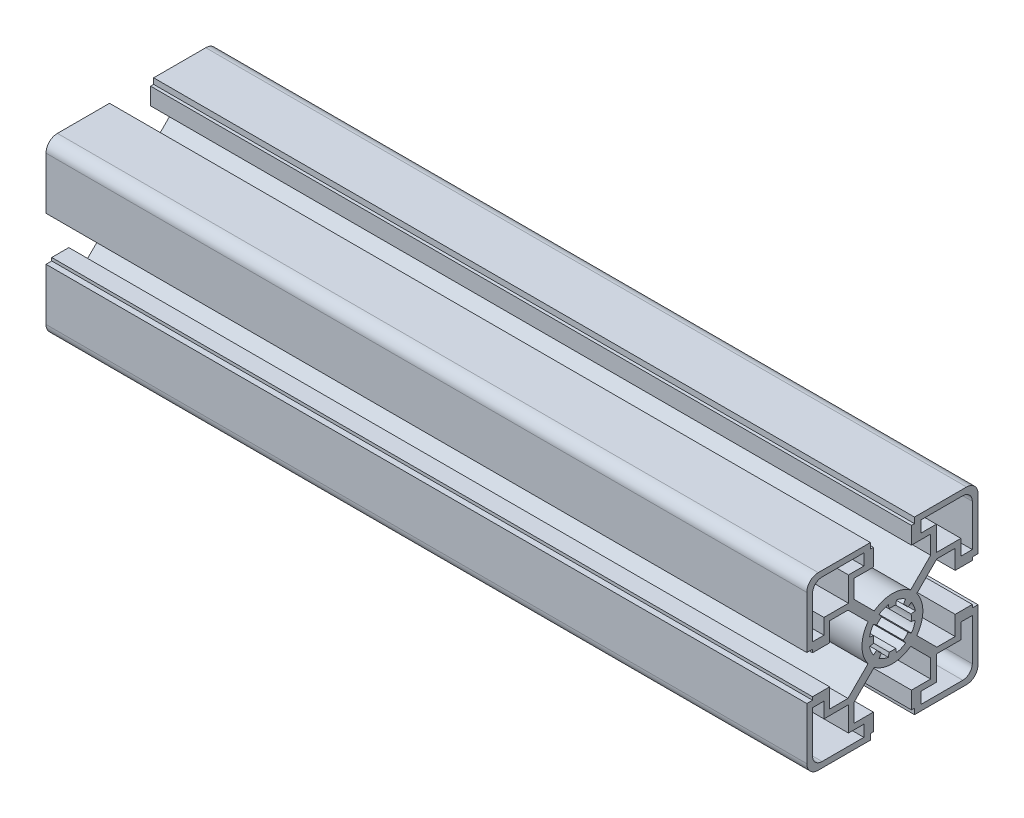
from build123d import *

# Parameters (mm, degrees)
BR_EXTRUDE_DEPTH      = 122.5
BR_EXTRUDE_DEPTH_BACK = 77.5


with BuildPart() as part:
    # Sketch2 → BR_Extrude (new body, two sides)
    with BuildSketch(Plane(origin=(0, 0, 0), x_dir=(0, 0, -1), z_dir=(1, 0, 0))) as br_extrude_sk:
        with BuildLine():
            Line((-10.05, 11.676345597), (-10.05, 16.5))
            Line((-10.05, 16.5), (-5, 16.5))
            Line((-5, 16.5), (-5, 21))
            Line((-5, 21), (-5.8, 21))
            Line((-5.8, 21), (-5.8, 22.5))
            Line((-5.8, 22.5), (-19.5, 22.5))
            ThreePointArc((-19.5, 22.5), (-21.621320344, 21.621320344), (-22.5, 19.5))
            Line((-22.5, 19.5), (-22.5, 5.8))
            Line((-22.5, 5.8), (-21, 5.8))
            Line((-21, 5.8), (-21, 5))
            Line((-21, 5), (-16.5, 5))
            Line((-16.5, 5), (-16.5, 10.05))
            Line((-16.5, 10.05), (-11.676345597, 10.05))
            Line((-11.676345597, 10.05), (-6.411275155, 4.784929559))
            ThreePointArc((-6.411275155, 4.784929559), (-8, 0), (-6.411275155, -4.784929559))
            Line((-6.411275155, -4.784929559), (-11.676345597, -10.05))
            Line((-11.676345597, -10.05), (-16.5, -10.05))
            Line((-16.5, -10.05), (-16.5, -5))
            Line((-16.5, -5), (-21, -5))
            Line((-21, -5), (-21, -5.8))
            Line((-21, -5.8), (-22.5, -5.8))
            Line((-22.5, -5.8), (-22.5, -19.5))
            ThreePointArc((-22.5, -19.5), (-21.621320344, -21.621320344), (-19.5, -22.5))
            Line((-19.5, -22.5), (-5.8, -22.5))
            Line((-5.8, -22.5), (-5.8, -21))
            Line((-5.8, -21), (-5, -21))
            Line((-5, -21), (-5, -16.5))
            Line((-5, -16.5), (-10.05, -16.5))
            Line((-10.05, -16.5), (-10.05, -11.676345597))
            Line((-10.05, -11.676345597), (-4.784929559, -6.411275155))
            ThreePointArc((-4.784929559, -6.411275155), (0, -8), (4.784929559, -6.411275155))
            Line((4.784929559, -6.411275155), (10.05, -11.676345597))
            Line((10.05, -11.676345597), (10.05, -16.5))
            Line((10.05, -16.5), (5, -16.5))
            Line((5, -16.5), (5, -21))
            Line((5, -21), (5.8, -21))
            Line((5.8, -21), (5.8, -22.5))
            Line((5.8, -22.5), (19.5, -22.5))
            ThreePointArc((19.5, -22.5), (21.621320344, -21.621320344), (22.5, -19.5))
            Line((22.5, -19.5), (22.5, -5.8))
            Line((22.5, -5.8), (21, -5.8))
            Line((21, -5.8), (21, -5))
            Line((21, -5), (16.5, -5))
            Line((16.5, -5), (16.5, -10.05))
            Line((16.5, -10.05), (11.676345597, -10.05))
            Line((11.676345597, -10.05), (6.411275155, -4.784929559))
            ThreePointArc((6.411275155, -4.784929559), (8, 0), (6.411275155, 4.784929559))
            Line((6.411275155, 4.784929559), (11.676345597, 10.05))
            Line((11.676345597, 10.05), (16.5, 10.05))
            Line((16.5, 10.05), (16.5, 5))
            Line((16.5, 5), (21, 5))
            Line((21, 5), (21, 5.8))
            Line((21, 5.8), (22.5, 5.8))
            Line((22.5, 5.8), (22.5, 19.5))
            ThreePointArc((22.5, 19.5), (21.621320344, 21.621320344), (19.5, 22.5))
            Line((19.5, 22.5), (5.8, 22.5))
            Line((5.8, 22.5), (5.8, 21))
            Line((5.8, 21), (5, 21))
            Line((5, 21), (5, 16.5))
            Line((5, 16.5), (10.05, 16.5))
            Line((10.05, 16.5), (10.05, 11.676345597))
            Line((10.05, 11.676345597), (4.784929559, 6.411275155))
            ThreePointArc((4.784929559, 6.411275155), (0, 8), (-4.784929559, 6.411275155))
            Line((-4.784929559, 6.411275155), (-10.05, 11.676345597))
        make_face()
        with BuildLine():
            Line((11.55, 11.55), (11.55, 18))
            Line((11.55, 18), (7.5, 18))
            Line((7.5, 18), (7.5, 21))
            Line((7.5, 21), (18.5, 21))
            ThreePointArc((18.5, 21), (20.267766953, 20.267766953), (21, 18.5))
            Line((21, 18.5), (21, 7.5))
            Line((21, 7.5), (18, 7.5))
            Line((18, 7.5), (18, 11.55))
            Line((18, 11.55), (11.55, 11.55))
        make_face(mode=Mode.SUBTRACT)
        with BuildLine():
            Line((11.55, -11.55), (18, -11.55))
            Line((18, -11.55), (18, -7.5))
            Line((18, -7.5), (21, -7.5))
            Line((21, -7.5), (21, -18.5))
            ThreePointArc((21, -18.5), (20.267766953, -20.267766953), (18.5, -21))
            Line((18.5, -21), (7.5, -21))
            Line((7.5, -21), (7.5, -18))
            Line((7.5, -18), (11.55, -18))
            Line((11.55, -18), (11.55, -11.55))
        make_face(mode=Mode.SUBTRACT)
        with BuildLine():
            Line((-11.55, 11.55), (-18, 11.55))
            Line((-18, 11.55), (-18, 7.5))
            Line((-18, 7.5), (-21, 7.5))
            Line((-21, 7.5), (-21, 18.5))
            ThreePointArc((-21, 18.5), (-20.267766953, 20.267766953), (-18.5, 21))
            Line((-18.5, 21), (-7.5, 21))
            Line((-7.5, 21), (-7.5, 18))
            Line((-7.5, 18), (-11.55, 18))
            Line((-11.55, 18), (-11.55, 11.55))
        make_face(mode=Mode.SUBTRACT)
        with BuildLine():
            Line((-11.55, -11.55), (-11.55, -18))
            Line((-11.55, -18), (-7.5, -18))
            Line((-7.5, -18), (-7.5, -21))
            Line((-7.5, -21), (-18.5, -21))
            ThreePointArc((-18.5, -21), (-20.267766953, -20.267766953), (-21, -18.5))
            Line((-21, -18.5), (-21, -7.5))
            Line((-21, -7.5), (-18, -7.5))
            Line((-18, -7.5), (-18, -11.55))
            Line((-18, -11.55), (-11.55, -11.55))
        make_face(mode=Mode.SUBTRACT)
        with BuildLine():
            Line((-6.007327293, -1.059253884), (-4.924038765, -0.868240888))
            ThreePointArc((-4.924038765, -0.868240888), (-5, 0), (-4.924038765, 0.868240888))
            Line((-4.924038765, 0.868240888), (-6.007327293, 1.059253884))
            ThreePointArc((-6.007327293, 1.059253884), (-5.635665148, 2.334368937), (-4.99682747, 3.498816262))
            Line((-4.99682747, 3.498816262), (-4.095760221, 2.867882182))
            ThreePointArc((-4.095760221, 2.867882182), (-3.535533906, 3.535533906), (-2.867882182, 4.095760221))
            Line((-2.867882182, 4.095760221), (-3.498816262, 4.99682747))
            ThreePointArc((-3.498816262, 4.99682747), (-2.334368937, 5.635665148), (-1.059253884, 6.007327293))
            Line((-1.059253884, 6.007327293), (-0.868240888, 4.924038765))
            ThreePointArc((-0.868240888, 4.924038765), (0, 5), (0.868240888, 4.924038765))
            Line((0.868240888, 4.924038765), (1.059253884, 6.007327293))
            ThreePointArc((1.059253884, 6.007327293), (2.334368937, 5.635665148), (3.498816262, 4.99682747))
            Line((3.498816262, 4.99682747), (2.867882182, 4.095760221))
            ThreePointArc((2.867882182, 4.095760221), (3.535533906, 3.535533906), (4.095760221, 2.867882182))
            Line((4.095760221, 2.867882182), (4.99682747, 3.498816262))
            ThreePointArc((4.99682747, 3.498816262), (5.635665148, 2.334368937), (6.007327293, 1.059253884))
            Line((6.007327293, 1.059253884), (4.924038765, 0.868240888))
            ThreePointArc((4.924038765, 0.868240888), (5, 0), (4.924038765, -0.868240888))
            Line((4.924038765, -0.868240888), (6.007327293, -1.059253884))
            ThreePointArc((6.007327293, -1.059253884), (5.635665148, -2.334368937), (4.99682747, -3.498816262))
            Line((4.99682747, -3.498816262), (4.095760221, -2.867882182))
            ThreePointArc((4.095760221, -2.867882182), (3.535533906, -3.535533906), (2.867882182, -4.095760221))
            Line((2.867882182, -4.095760221), (3.498816262, -4.99682747))
            ThreePointArc((3.498816262, -4.99682747), (2.334368937, -5.635665148), (1.059253884, -6.007327293))
            Line((1.059253884, -6.007327293), (0.868240888, -4.924038765))
            ThreePointArc((0.868240888, -4.924038765), (0, -5), (-0.868240888, -4.924038765))
            Line((-0.868240888, -4.924038765), (-1.059253884, -6.007327293))
            ThreePointArc((-1.059253884, -6.007327293), (-2.334368937, -5.635665148), (-3.498816262, -4.99682747))
            Line((-3.498816262, -4.99682747), (-2.867882182, -4.095760221))
            ThreePointArc((-2.867882182, -4.095760221), (-3.535533906, -3.535533906), (-4.095760221, -2.867882182))
            Line((-4.095760221, -2.867882182), (-4.99682747, -3.498816262))
            ThreePointArc((-4.99682747, -3.498816262), (-5.635665148, -2.334368937), (-6.007327293, -1.059253884))
        make_face(mode=Mode.SUBTRACT)
    extrude(amount=BR_EXTRUDE_DEPTH)
    extrude(br_extrude_sk.sketch, amount=-BR_EXTRUDE_DEPTH_BACK)


solid = part.part
